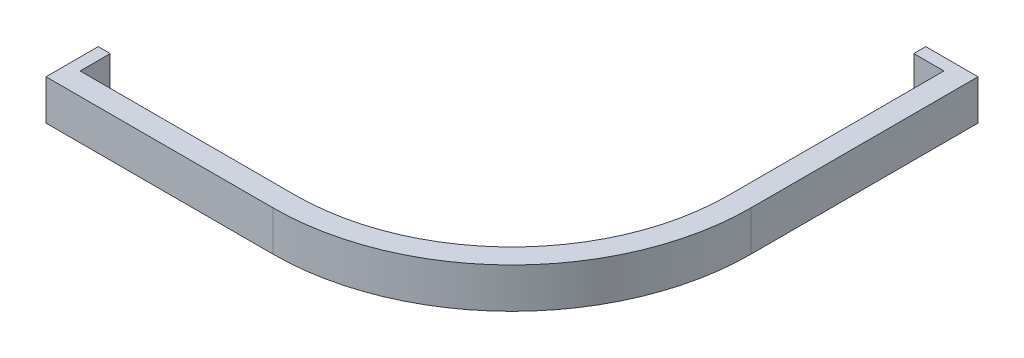
from build123d import *

# Parameters (mm, degrees)
BOSS_EXTRUDE1_DEPTH = 10


with BuildPart() as part:
    # Sketch1 → Boss-Extrude1 (new body)
    with BuildSketch(Plane(origin=(0, 0, 0), x_dir=(1, 0, 0), z_dir=(0, 1, 0))):
        with BuildLine():
            Line((0, -116.07), (56.57, -116.07))
            ThreePointArc((56.57, -116.07), (98.642853481, -98.642853481), (116.07, -56.57))
            Line((116.07, -56.57), (116.07, 0))
            Line((116.07, 0), (103.07, 0))
            Line((103.07, 0), (103.07, -3))
            Line((103.07, -3), (110.57, -3))
            Line((110.57, -3), (110.57, -56.57))
            ThreePointArc((110.57, -56.57), (94.753766184, -94.753766184), (56.57, -110.57))
            Line((56.57, -110.57), (3, -110.57))
            Line((3, -110.57), (3, -103.07))
            Line((3, -103.07), (0, -103.07))
            Line((0, -103.07), (0, -116.07))
        make_face()
    extrude(amount=BOSS_EXTRUDE1_DEPTH)


solid = part.part
